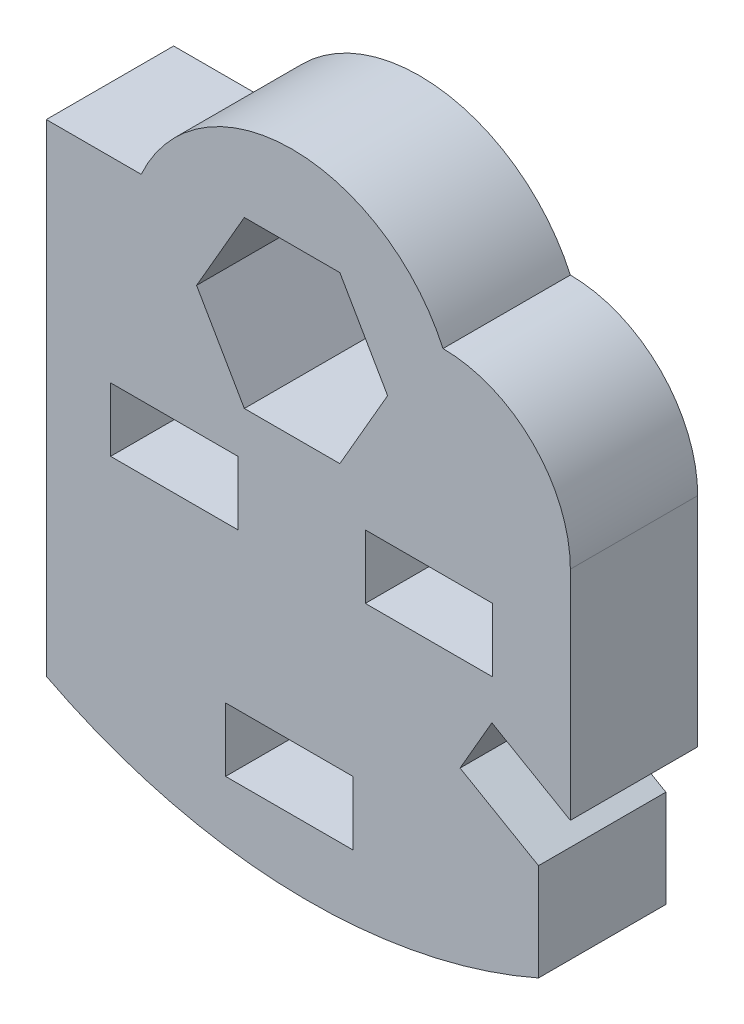
from build123d import *

# Parameters (mm, degrees)
SKETCH1_W           = 4
SKETCH1_H           = 2
BOSS_EXTRUDE1_DEPTH = 4


with BuildPart() as part:
    # Sketch1 → Boss-Extrude1 (new body)
    with BuildSketch(Plane.XY):
        with BuildLine():
            Line((14.475572066, 6), (15.475572066, 7.732050808))
            Line((15.475572066, 7.732050808), (17.939673681, 6.309401077))
            Line((17.939673681, 6.309401077), (17.939673681, 13.142551265))
            ThreePointArc((17.939673681, 13.142551265), (16.768100806, 15.97097839), (13.939673681, 17.142551265))
            ThreePointArc((13.939673681, 17.142551265), (9.2, 20.197069168), (4.460326319, 17.142551265))
            Line((4.460326319, 17.142551265), (1.48, 17.142551265))
            Line((1.48, 17.142551265), (1.48, 2))
            ThreePointArc((1.48, 2), (9.155654032, 0.008565204), (16.939673681, 1.522010102))
            Line((16.939673681, 1.522010102), (16.939673681, 4.577350269))
            Line((16.939673681, 4.577350269), (14.475572066, 6))
        make_face()
        with Locations((5.5, 9.99107808)):
            Rectangle(SKETCH1_W, SKETCH1_H, mode=Mode.SUBTRACT)
        with Locations((9.111056117, 3.09107808)):
            Rectangle(SKETCH1_W, SKETCH1_H, mode=Mode.SUBTRACT)
        with Locations((13.5, 9.99107808)):
            Rectangle(SKETCH1_W, SKETCH1_H, mode=Mode.SUBTRACT)
        Polygon((6.2, 14.99107808), (7.7, 12.393001869), (10.7, 12.393001869), (12.2, 14.99107808), (10.7, 17.589154291), (7.7, 17.589154291), align=None, mode=Mode.SUBTRACT)
    extrude(amount=BOSS_EXTRUDE1_DEPTH)


solid = part.part
